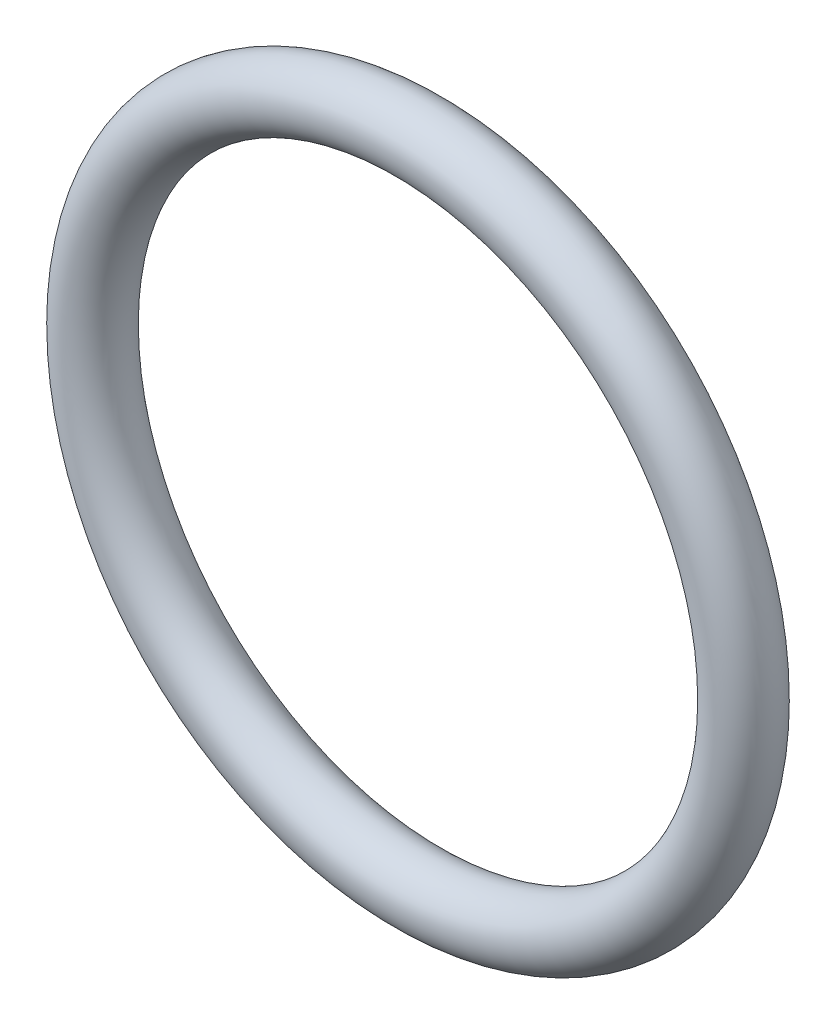
from build123d import *

# Parameters (mm, degrees)
SKETCH2_R = 1.2


with BuildPart() as part:
    # Sweep1: sweep along a path in Sketch1
    with BuildLine(Plane.XY) as sweep1_path:
        CenterArc((0, 0), 10.85, 0, 360)
    # Sketch2 → Sweep1 (sweep)
    with BuildSketch(Plane(origin=(0, 0, 0), x_dir=(1, 0, 0), z_dir=(0, 1, 0))):
        with Locations((-12.05, 0)):
            Circle(SKETCH2_R)
    sweep(path=sweep1_path.line)


solid = part.part
